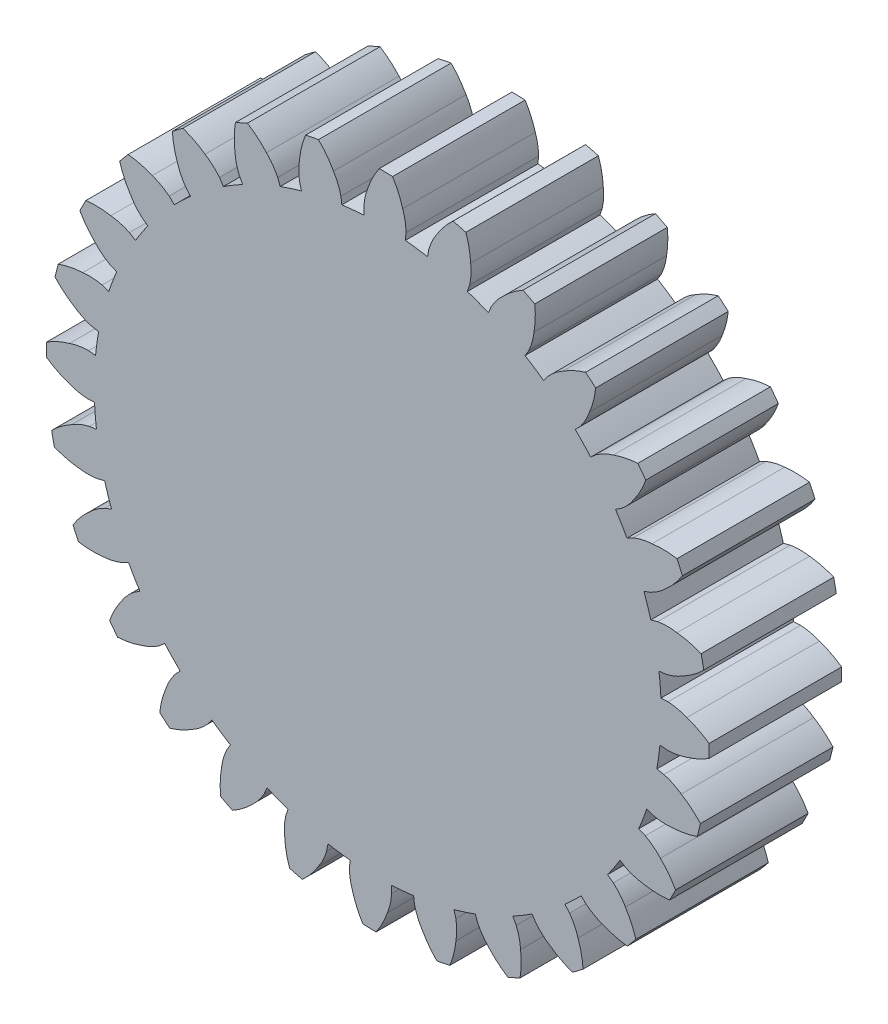
from build123d import *

# Parameters (mm, degrees)
RESSALTO_EXTRUS_O1_DEPTH = 300
PADR_OCIRCULAR1_COUNT    = 28


with BuildPart() as part:
    # Esboço2 → Ressalto-extrusão1 (new body, symmetric)
    with BuildSketch(Plane.XY):
        with BuildLine():
            Line((513.500159303, 1211.193373866), (500.91197935, 1181.501620373))
            ThreePointArc((500.91197935, 1181.501620373), (-585.333992841, -1142.034590906), (666.669243106, 1096.54503341))
            Line((666.669243106, 1096.54503341), (683.422989767, 1124.101783451))
            ThreePointArc((683.422989767, 1124.101783451), (698.988842989, 1165.093257122), (707.41688311, 1208.123070507))
            ThreePointArc((707.41688311, 1208.123070507), (713.125511786, 1264.427067255), (710.667302081, 1320.966307577))
            ThreePointArc((710.667302081, 1320.966307577), (684.174385772, 1334.88029795), (657.409176041, 1348.263021542))
            ThreePointArc((657.409176041, 1348.263021542), (610.07443348, 1317.244468419), (567.699411925, 1279.733322884))
            ThreePointArc((567.699411925, 1279.733322884), (537.688467761, 1247.765527674), (513.500159303, 1211.193373866))
        make_face()
    ressalto_extrus_o1 = extrude(amount=RESSALTO_EXTRUS_O1_DEPTH, both=True)

    # PadrãoCircular1: Ressalto-extrusão1 ×28 about axis
    padr_ocircular1_axis = Axis((0, 0, 0), (0, 0, 1))
    for i in range(1, PADR_OCIRCULAR1_COUNT):
        add(ressalto_extrus_o1.rotate(padr_ocircular1_axis, i * 360 / PADR_OCIRCULAR1_COUNT))


solid = part.part
